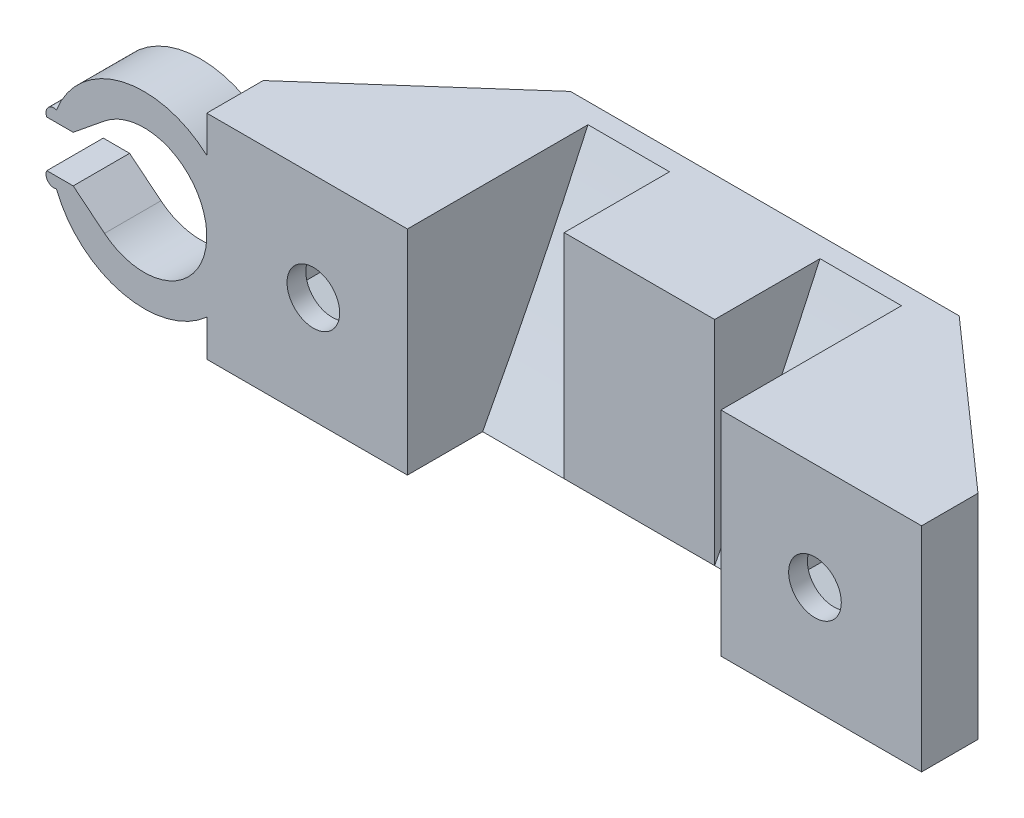
from build123d import *

# Parameters (mm, degrees)
BOSS_EXTRUDE1_DEPTH = 17
BOSS_EXTRUDE2_DEPTH = 2
BOSS_EXTRUDE3_DEPTH = 2
SKETCH4_R           = 2.1
CUT_EXTRUDE1_DEPTH  = 100
CUT_EXTRUDE2_DEPTH  = 3
CUT_EXTRUDE3_DEPTH  = 6.5
CUT_EXTRUDE4_DEPTH  = 6.5
BOSS_EXTRUDE4_DEPTH = 4.5


with BuildPart() as part:
    # Sketch1 → Boss-Extrude1 (new body)
    with BuildSketch(Plane(origin=(0, 0, 0), x_dir=(1, 0, 0), z_dir=(0, 1, 0))):
        Polygon((-27.582659514, 44.185105583), (-2.582659514, 44.185105583), (-2.582659514, 38.185105583), (13.417340486, 38.185105583), (13.417340486, 42.685105583), (0.417340486, 42.685105583), (0.417340486, 54.185105583), (-30.582659514, 54.185105583), (-30.582659514, 42.685105583), (-43.582659514, 42.685105583), (-43.582659514, 38.185105583), (-27.582659514, 38.185105583), align=None)
    extrude(amount=BOSS_EXTRUDE1_DEPTH)

    # Sketch2 → Boss-Extrude2 (add)
    with BuildSketch(Plane(origin=(0, 17, 0), x_dir=(1, 0, 0), z_dir=(0, 1, 0))):
        Polygon((-43.582659514, 42.685105583), (-30.582659514, 54.185105583), (-30.582659514, 42.685105583), align=None)
        Polygon((0.417340486, 42.685105583), (13.417340486, 42.685105583), (0.417340486, 54.185105583), align=None)
    extrude(amount=-BOSS_EXTRUDE2_DEPTH)

    # Sketch3 → Boss-Extrude3 (add)
    with BuildSketch(Plane.XZ):
        Polygon((-43.582659514, -42.685105583), (-30.582659514, -54.185105583), (-30.582659514, -42.685105583), align=None)
        Polygon((0.417340486, -42.685105583), (0.417340486, -54.185105583), (13.417340486, -42.685105583), align=None)
    extrude(amount=-BOSS_EXTRUDE3_DEPTH)

    # Sketch4 → Cut-Extrude1 (cut)
    with BuildSketch(Plane.XY.offset(-38.185105583)):
        with Locations((-35.082659514, 8.5)):
            Circle(SKETCH4_R)
        with Locations((4.917340486, 8.5)):
            Circle(SKETCH4_R)
    extrude(amount=-CUT_EXTRUDE1_DEPTH, mode=Mode.SUBTRACT)

    # Sketch5 → Cut-Extrude2 (cut)
    with BuildSketch(Plane(origin=(0, 0, -42.685105583), x_dir=(-1, 0, 0), z_dir=(0, 0, -1))):
        Polygon((31.582659514, 6.479274058), (31.582659514, 10.520725942), (35.082659514, 12.541451884), (38.582659514, 10.520725942), (38.582659514, 6.479274058), (35.082659514, 4.458548116), align=None)
        Polygon((-1.417340486, 10.520725942), (-4.917340486, 12.541451884), (-8.417340486, 10.520725942), (-8.417340486, 6.479274058), (-4.917340486, 4.458548116), (-1.417340486, 6.479274058), align=None)
    extrude(amount=-CUT_EXTRUDE2_DEPTH, mode=Mode.SUBTRACT)

    # Sketch7 → Cut-Extrude3 (cut)
    with BuildSketch(Plane.ZY.offset(2.582659514)):
        with BuildLine():
            Line((-53.601964627, 19.27795803), (-35.36636136, 18.147314128))
            Line((-35.36636136, 18.147314128), (-35.36636136, -6.291096758))
            Line((-35.36636136, -6.291096758), (-39.347618514, -8.620327672))
            ThreePointArc((-39.347618514, -8.620327672), (-46.872397507, 5.125662458), (-53.601964627, 19.27795803))
        make_face()
    extrude(amount=CUT_EXTRUDE3_DEPTH, mode=Mode.SUBTRACT)

    # Sketch8 → Cut-Extrude4 (cut)
    with BuildSketch(Plane(origin=(-27.582659514, 0, 0), x_dir=(0, 0, -1), z_dir=(1, 0, 0))):
        with BuildLine():
            Line((60.133248532, 35.4590838), (29.94533861, 35.4590838))
            Line((29.94533861, 35.4590838), (34.196090785, -17.072827801))
            ThreePointArc((34.196090785, -17.072827801), (48.567589168, 8.50044914), (60.133248532, 35.4590838))
        make_face()
    extrude(amount=CUT_EXTRUDE4_DEPTH, mode=Mode.SUBTRACT)

    # Sketch9 → Boss-Extrude4 (add)
    with BuildSketch(Plane.XY.offset(-38.185105583)):
        with BuildLine():
            Line((-51.736745863, 12.379657112), (-54.233308347, 10.35))
            Line((-54.233308347, 10.35), (-56.336651381, 10.35))
            ThreePointArc((-56.336651381, 10.35), (-56.247164307, 11.045699168), (-55.569469191, 11.226626221))
            ThreePointArc((-55.569469191, 11.226626221), (-41.082659514, 8.5), (-55.569469191, 5.773373779))
            ThreePointArc((-55.569469191, 5.773373779), (-56.247164307, 5.954300832), (-56.336651381, 6.65))
            Line((-56.336651381, 6.65), (-54.233308347, 6.65))
            Line((-54.233308347, 6.65), (-51.736745863, 4.620342888))
            ThreePointArc((-51.736745863, 4.620342888), (-43.582659514, 8.5), (-51.736745863, 12.379657112))
        make_face()
    extrude(amount=-BOSS_EXTRUDE4_DEPTH)


solid = part.part
